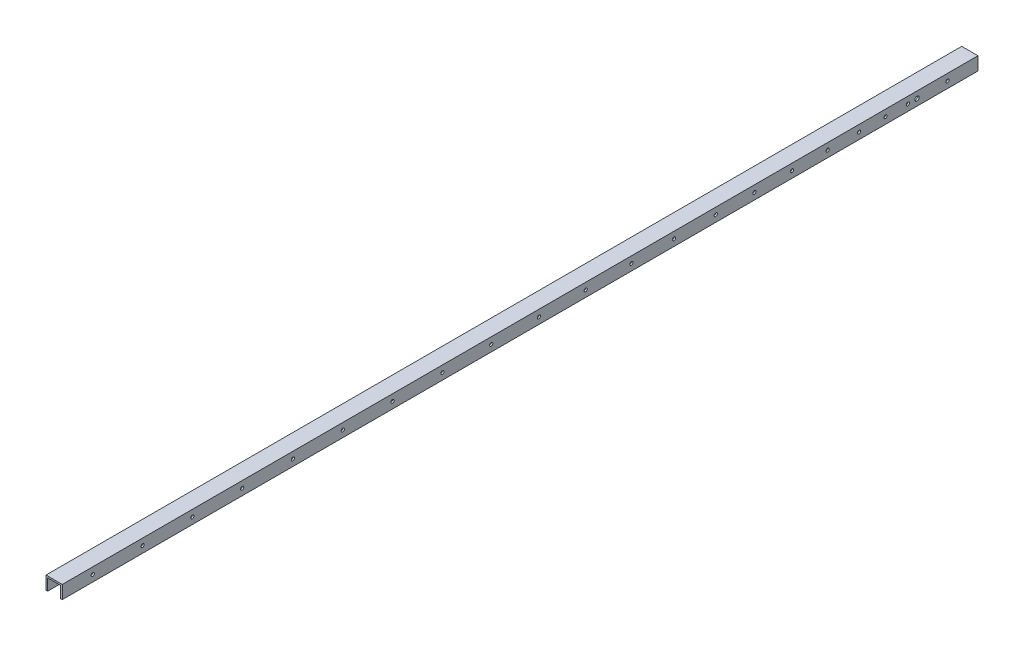
from build123d import *

# Parameters (mm, degrees)
BOSS_EXTRUDE1_DEPTH = 450.5
SKETCH2_R           = 1.5875
SKETCH2_R_2         = 2.1
CUT_EXTRUDE1_DEPTH  = 17


with BuildPart() as part:
    # Sketch1 → Boss-Extrude1 (new body, symmetric)
    with BuildSketch(Plane.XY):
        Polygon((-8, 6.5), (8, 6.5), (8, -6.5), (6.4, -6.5), (6.4, 4.9), (-6.4, 4.9), (-6.4, -6.5), (-8, -6.5), align=None)
    extrude(amount=BOSS_EXTRUDE1_DEPTH, both=True)

    # Sketch2 → Cut-Extrude1 (cut, through all)
    with BuildSketch(Plane(origin=(8, 0, 0), x_dir=(0, 0, -1), z_dir=(1, 0, 0))):
        with Locations((-371.5, 0)):
            Circle(SKETCH2_R)
        with Locations((-322.5, 0)):
            Circle(SKETCH2_R)
        with Locations((-273.5, 0)):
            Circle(SKETCH2_R)
        with Locations((-420.5, 0)):
            Circle(SKETCH2_R)
        with Locations((-223.5, 0)):
            Circle(SKETCH2_R)
        with Locations((-174.5, 0)):
            Circle(SKETCH2_R)
        with Locations((-125.5, 0)):
            Circle(SKETCH2_R)
        with Locations((-76.5, 0)):
            Circle(SKETCH2_R)
        with Locations((-28.5, 0)):
            Circle(SKETCH2_R)
        with Locations((18.5, 0)):
            Circle(SKETCH2_R)
        with Locations((64.5, 0)):
            Circle(SKETCH2_R)
        with Locations((109.5, 0)):
            Circle(SKETCH2_R)
        with Locations((151.5, 0)):
            Circle(SKETCH2_R)
        with Locations((192.5, 0)):
            Circle(SKETCH2_R)
        with Locations((230.5, 0)):
            Circle(SKETCH2_R)
        with Locations((267.5, 0)):
            Circle(SKETCH2_R)
        with Locations((302.5, 0)):
            Circle(SKETCH2_R)
        with Locations((333.5, 0)):
            Circle(SKETCH2_R)
        with Locations((359.5, 0)):
            Circle(SKETCH2_R)
        with Locations((381.5, 0)):
            Circle(SKETCH2_R)
        with Locations((420.5, 0)):
            Circle(SKETCH2_R)
        with Locations((390.5, 0)):
            Circle(SKETCH2_R_2)
    extrude(amount=-CUT_EXTRUDE1_DEPTH, mode=Mode.SUBTRACT)


solid = part.part
